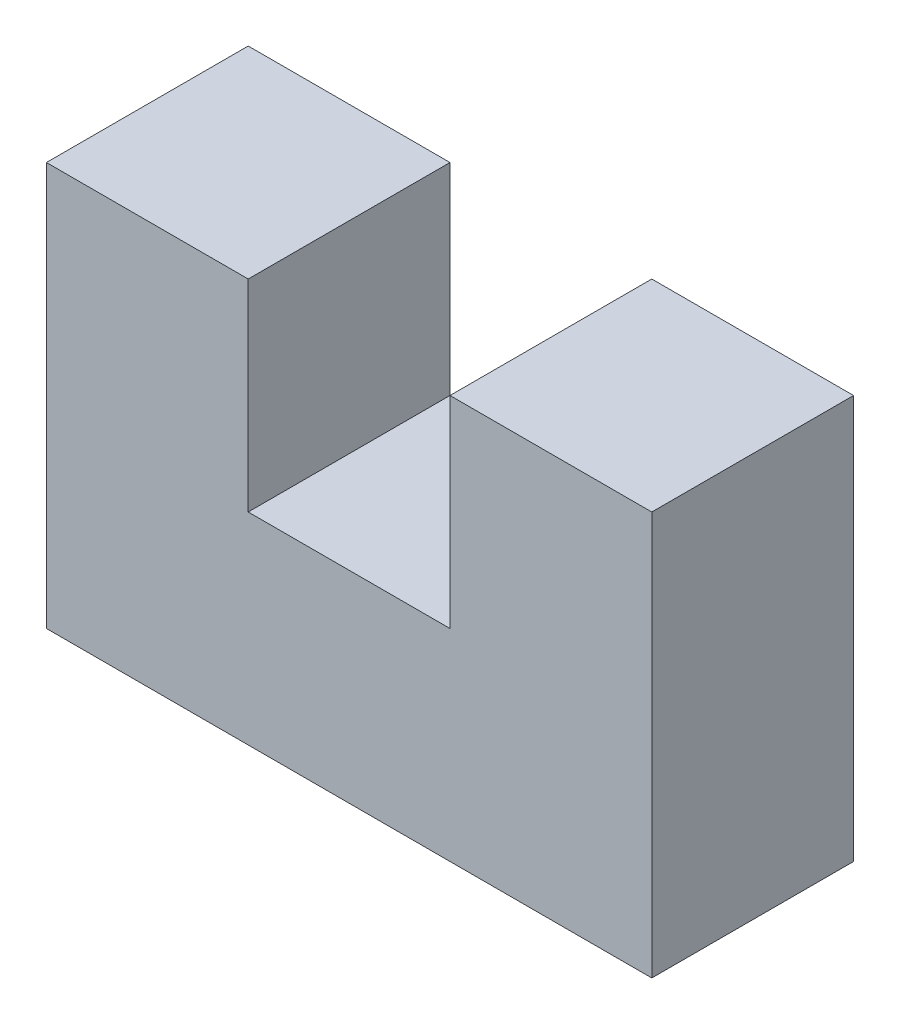
from build123d import *

# Parameters (mm, degrees)
BOSS_EXTRUDE1_DEPTH = 25.4


with BuildPart() as part:
    # Sketch1 → Boss-Extrude1 (new body)
    with BuildSketch(Plane.XY):
        Polygon((0, 50.8), (0, 0), (76.2, 0), (76.2, 50.8), (50.8, 50.8), (50.8, 25.4), (25.4, 25.4), (25.4, 50.8), align=None)
    extrude(amount=BOSS_EXTRUDE1_DEPTH)


solid = part.part
